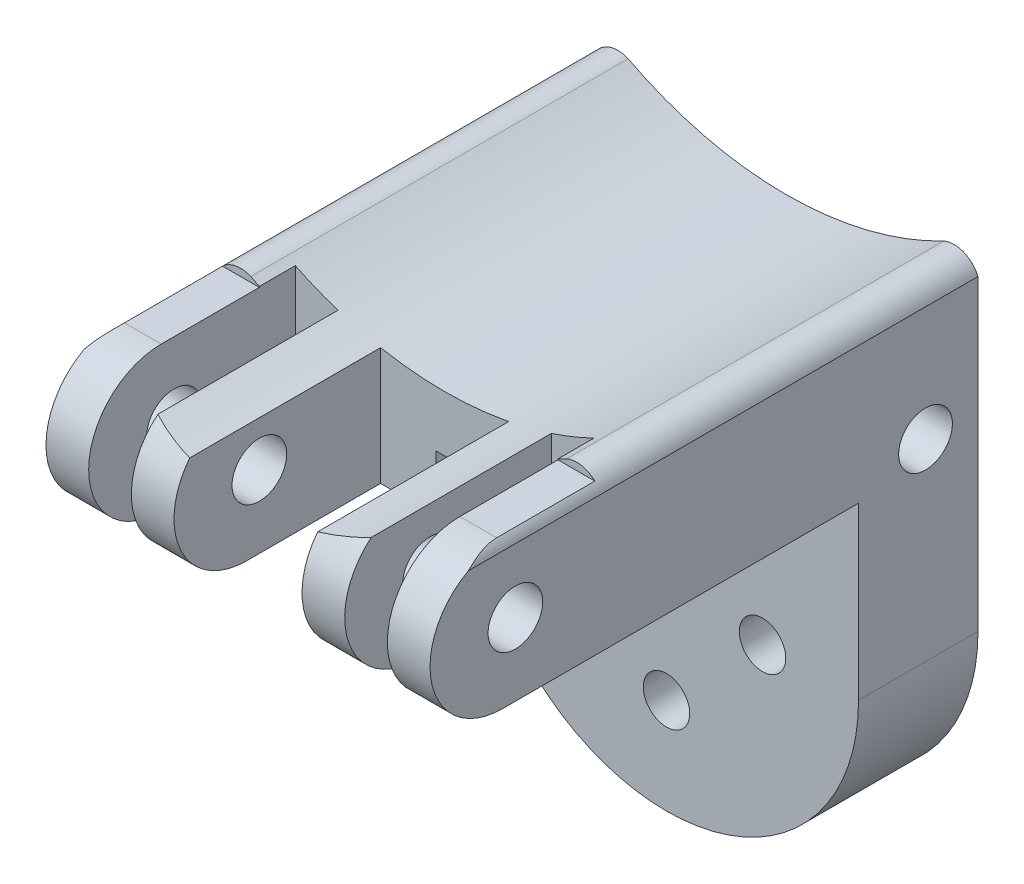
from build123d import *

# Parameters (mm, degrees)
BOSS_EXTRUDE1_DEPTH = 20
CUT_EXTRUDE23_DEPTH = 444
CUT_EXTRUDE26_DEPTH = 444
BOSS_EXTRUDE2_DEPTH = 14
SKETCH15_R          = 2.72
CUT_EXTRUDE27_DEPTH = 14
SKETCH16_R          = 3.25
SKETCH16_R_2        = 3.15
CUT_EXTRUDE28_DEPTH = 45
CUT_EXTRUDE29_DEPTH = 6.15
CUT_EXTRUDE31_DEPTH = 45
SKETCH18_R          = 3.2
CUT_EXTRUDE32_DEPTH = 45


with BuildPart() as part:
    # Sketch1 → Boss-Extrude1 (new body)
    with BuildSketch(Plane(origin=(0, 0, 0), x_dir=(1, 0, 0), z_dir=(0, 1, 0))):
        Polygon((-22.5, 328), (-17.5, 328), (-17.5, 352.208543952), (-12.5, 352.208543952), (-12.5, 328), (-7.5, 328), (-7.5, 352.208543952), (-2.5, 352.208543952), (2.5, 352.208543952), (7.5, 352.208543952), (7.5, 328), (12.5, 328), (12.5, 352.208543952), (17.5, 352.208543952), (17.5, 328), (22.5, 328), (22.5, 392.208543952), (-22.5, 392.208543952), align=None)
    extrude(amount=BOSS_EXTRUDE1_DEPTH)

    # Sketch2 → Cut-Extrude23 (cut)
    with BuildSketch(Plane.XY.offset(50)):
        with BuildLine():
            Line((-22.5, 20), (22.5, 20))
            Line((22.5, 20), (22.5, 16))
            ThreePointArc((22.5, 16), (20.832845478, 17.631987193), (18.5, 17.607120136))
            ThreePointArc((18.5, 17.607120136), (0, 13.071891388), (-18.5, 17.607120136))
            ThreePointArc((-18.5, 17.607120136), (-20.832845478, 17.631987193), (-22.5, 16))
            Line((-22.5, 16), (-22.5, 20))
        make_face()
    extrude(amount=-CUT_EXTRUDE23_DEPTH, mode=Mode.SUBTRACT)

    # Sketch12 → Cut-Extrude26 (cut)
    with BuildSketch(Plane.XY.offset(50)):
        Polygon((-1, 3.35), (-1, 6.55), (0, 6.55), (1, 6.55), (1, 3.35), align=None)
    extrude(amount=-CUT_EXTRUDE26_DEPTH, mode=Mode.SUBTRACT)

    # Sketch14 → Boss-Extrude2 (add)
    with BuildSketch(Plane(origin=(0, 0, -392.208543952), x_dir=(-1, 0, 0), z_dir=(0, 0, -1))):
        with BuildLine():
            Line((-22.5, 0), (-22.5, -20))
            ThreePointArc((-22.5, -20), (0, -42.5), (22.5, -20))
            Line((22.5, -20), (22.5, 0))
            Line((22.5, 0), (-22.5, 0))
        make_face()
    extrude(amount=-BOSS_EXTRUDE2_DEPTH)

    # Sketch15 → Cut-Extrude27 (cut)
    with BuildSketch(Plane(origin=(0, 0, -392.208543952), x_dir=(-1, 0, 0), z_dir=(0, 0, -1))):
        with Locations((11.25, -20)):
            Circle(SKETCH15_R)
        with Locations((0, -6.75)):
            Circle(SKETCH15_R)
        with Locations((-11.25, -20)):
            Circle(SKETCH15_R)
        with Locations((0, -31.25)):
            Circle(SKETCH15_R)
    extrude(amount=-CUT_EXTRUDE27_DEPTH, mode=Mode.SUBTRACT)

    # Sketch16 → Cut-Extrude28 (cut)
    with BuildSketch(Plane.ZY.offset(22.5)):
        with Locations((-1.25, 8.5)):
            Circle(SKETCH16_R)
        with Locations((-386.058543952, 2.588831384)):
            Circle(SKETCH16_R_2)
    extrude(amount=-CUT_EXTRUDE28_DEPTH, mode=Mode.SUBTRACT)

    # Sketch17 → Cut-Extrude29 (cut)
    with BuildSketch(Plane(origin=(0, 0, -392.208543952), x_dir=(-1, 0, 0), z_dir=(0, 0, -1))):
        Polygon((1, 8.5), (5, 8.5), (5, 2.5), (-5, 2.5), (-5, 8.5), (-1, 8.5), align=None)
    extrude(amount=-CUT_EXTRUDE29_DEPTH, mode=Mode.SUBTRACT)

    # Sketch8 → Cut-Extrude31 (cut)
    with BuildSketch(Plane(origin=(22.5, 0, 0), x_dir=(0, 0, -1), z_dir=(1, 0, 0))):
        with BuildLine():
            ThreePointArc((336.5, 0), (330.48959236, 2.48959236), (328, 8.5))
            Line((328, 8.5), (328, 0))
            Line((328, 0), (336.5, 0))
        make_face()
        with BuildLine():
            Line((336.5, 20), (328, 20))
            Line((328, 20), (328, 17))
            Line((328, 17), (328, 8.5))
            ThreePointArc((328, 8.5), (330.48959236, 14.51040764), (336.5, 17))
            Line((336.5, 17), (348, 17))
            Line((348, 17), (348, 20))
            Line((348, 20), (336.5, 20))
        make_face()
    extrude(amount=-CUT_EXTRUDE31_DEPTH, mode=Mode.SUBTRACT)

    # Sketch18 → Cut-Extrude32 (cut)
    with BuildSketch(Plane(origin=(22.5, 0, 0), x_dir=(0, 0, -1), z_dir=(1, 0, 0))):
        with Locations((338, 8.5)):
            Circle(SKETCH18_R)
    extrude(amount=-CUT_EXTRUDE32_DEPTH, mode=Mode.SUBTRACT)


solid = part.part
